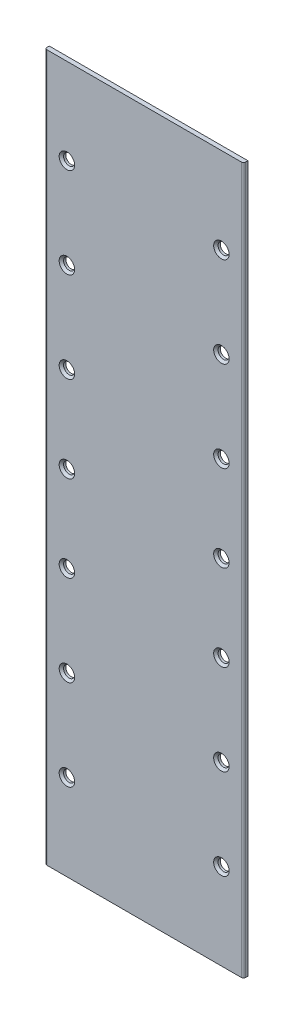
from build123d import *

# Parameters (mm, degrees)
ESQUISSE1_W             = 90
ESQUISSE1_H             = 320
BOSS_EXTRU_1_DEPTH      = 2
ESQUISSE2_R             = 2.5
ENL_V_MAT_EXTRU_1_DEPTH = 45
CONG_2_R                = 1
CHANFREIN1_SIZE         = 1


with BuildPart() as part:
    # Esquisse1 → Boss.-Extru.1 (new body)
    with BuildSketch(Plane.XY):
        Rectangle(ESQUISSE1_W, ESQUISSE1_H)
    extrude(amount=BOSS_EXTRU_1_DEPTH)

    # Esquisse2 → Enlèv. mat.-Extru.1 (cut)
    with BuildSketch(Plane.XY.offset(2)):
        with Locations((-35, 120.982014683)):
            Circle(ESQUISSE2_R)
        with Locations((35, 120.982014683)):
            Circle(ESQUISSE2_R)
        with Locations((35, 80)):
            Circle(ESQUISSE2_R)
        with Locations((-35, 80)):
            Circle(ESQUISSE2_R)
        with Locations((-35, 39.017985317)):
            Circle(ESQUISSE2_R)
        with Locations((35, 39.017985317)):
            Circle(ESQUISSE2_R)
        with Locations((35, 0)):
            Circle(ESQUISSE2_R)
        with Locations((-35, 0)):
            Circle(ESQUISSE2_R)
        with Locations((-35, -39.017985317)):
            Circle(ESQUISSE2_R)
        with Locations((35, -39.017985317)):
            Circle(ESQUISSE2_R)
        with Locations((35, -80)):
            Circle(ESQUISSE2_R)
        with Locations((-35, -80)):
            Circle(ESQUISSE2_R)
        with Locations((35, -120.982014683)):
            Circle(ESQUISSE2_R)
        with Locations((-35, -120.982014683)):
            Circle(ESQUISSE2_R)
    extrude(amount=-ENL_V_MAT_EXTRU_1_DEPTH, mode=Mode.SUBTRACT)

    # Congé2
    cong_2_edges = [part.edges().sort_by_distance(p)[0] for p in [
        (45, 0, 2),
        (-45, 0, 2),
    ]]
    fillet(cong_2_edges, radius=CONG_2_R)

    # Chanfrein1
    chanfrein1_edges = [part.edges().sort_by_distance(p)[0] for p in [
        (-37.5, -39.017985317, 2),
        (-37.5, 0, 2),
        (32.5, 0, 2),
        (32.5, 39.017985317, 2),
        (-37.5, 39.017985317, 2),
        (-37.5, 80, 2),
        (32.5, 80, 2),
        (32.5, 120.982014683, 2),
        (-37.5, -120.982014683, 2),
        (32.5, -39.017985317, 2),
        (32.5, -80, 2),
        (-37.5, -80, 2),
        (32.5, -120.982014683, 2),
        (-37.5, 120.982014683, 2),
    ]]
    chamfer(chanfrein1_edges, length=CHANFREIN1_SIZE)


solid = part.part
